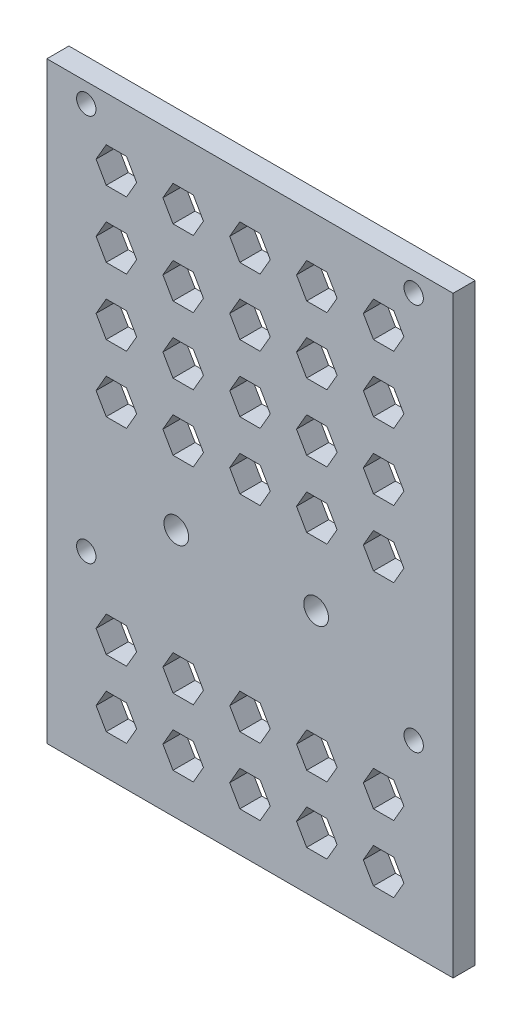
from build123d import *

# Parameters (mm, degrees)
SKETCH_1_W      = 60.8
SKETCH_1_H      = 88.755814015
SKETCH_1_R      = 1.45
SKETCH_1_R_2    = 1.85
EXTRUDE_1_DEPTH = 3.3


with BuildPart() as part:
    # Sketch 1 → Extrude 1 (new body)
    with BuildSketch(Plane.XY):
        with Locations((1.326158038, -1.737600889)):
            Rectangle(SKETCH_1_W, SKETCH_1_H)
        Polygon((-15.638485556, -37.518581742), (-17.156163759, -40.147277499), (-20.191520165, -40.147277499), (-21.709198368, -37.518581742), (-20.191520165, -34.889885985), (-17.156163759, -34.889885985), align=None, mode=Mode.SUBTRACT)
        Polygon((-15.638485556, -27.518581742), (-17.156163759, -30.147277499), (-20.191520165, -30.147277499), (-21.709198368, -27.518581742), (-20.191520165, -24.889885985), (-17.156163759, -24.889885985), align=None, mode=Mode.SUBTRACT)
        Polygon((-5.638485556, -37.518581742), (-7.156163759, -40.147277499), (-10.191520165, -40.147277499), (-11.709198368, -37.518581742), (-10.191520165, -34.889885985), (-7.156163759, -34.889885985), align=None, mode=Mode.SUBTRACT)
        Polygon((4.361514444, -37.518581742), (2.843836241, -40.147277499), (-0.191520165, -40.147277499), (-1.709198368, -37.518581742), (-0.191520165, -34.889885985), (2.843836241, -34.889885985), align=None, mode=Mode.SUBTRACT)
        Polygon((-5.638485556, -27.518581742), (-7.156163759, -30.147277499), (-10.191520165, -30.147277499), (-11.709198368, -27.518581742), (-10.191520165, -24.889885985), (-7.156163759, -24.889885985), align=None, mode=Mode.SUBTRACT)
        Polygon((4.361514444, -27.518581742), (2.843836241, -30.147277499), (-0.191520165, -30.147277499), (-1.709198368, -27.518581742), (-0.191520165, -24.889885985), (2.843836241, -24.889885985), align=None, mode=Mode.SUBTRACT)
        with Locations((-23.173841962, -18.259693882)):
            Circle(SKETCH_1_R, mode=Mode.SUBTRACT)
        with Locations((-9.7, -8.761035422)):
            Circle(SKETCH_1_R_2, mode=Mode.SUBTRACT)
        Polygon((14.361514444, -37.518581742), (12.843836241, -40.147277499), (9.808479835, -40.147277499), (8.290801632, -37.518581742), (9.808479835, -34.889885985), (12.843836241, -34.889885985), align=None, mode=Mode.SUBTRACT)
        Polygon((14.361514444, -27.518581742), (12.843836241, -30.147277499), (9.808479835, -30.147277499), (8.290801632, -27.518581742), (9.808479835, -24.889885985), (12.843836241, -24.889885985), align=None, mode=Mode.SUBTRACT)
        Polygon((24.361514444, -37.518581742), (22.843836241, -40.147277499), (19.808479835, -40.147277499), (18.290801632, -37.518581742), (19.808479835, -34.889885985), (22.843836241, -34.889885985), align=None, mode=Mode.SUBTRACT)
        Polygon((24.361514444, -27.518581742), (22.843836241, -30.147277499), (19.808479835, -30.147277499), (18.290801632, -27.518581742), (19.808479835, -24.889885985), (22.843836241, -24.889885985), align=None, mode=Mode.SUBTRACT)
        with Locations((11.226158038, -8.761035422)):
            Circle(SKETCH_1_R_2, mode=Mode.SUBTRACT)
        Polygon((-15.638485556, 3.308390173), (-17.156163759, 0.679694416), (-20.191520165, 0.679694416), (-21.709198368, 3.308390173), (-20.191520165, 5.93708593), (-17.156163759, 5.93708593), align=None, mode=Mode.SUBTRACT)
        Polygon((-15.638485556, 13.308390173), (-17.156163759, 10.679694416), (-20.191520165, 10.679694416), (-21.709198368, 13.308390173), (-20.191520165, 15.93708593), (-17.156163759, 15.93708593), align=None, mode=Mode.SUBTRACT)
        Polygon((-5.638485556, 3.308390173), (-7.156163759, 0.679694416), (-10.191520165, 0.679694416), (-11.709198368, 3.308390173), (-10.191520165, 5.93708593), (-7.156163759, 5.93708593), align=None, mode=Mode.SUBTRACT)
        Polygon((4.361514444, 3.308390173), (2.843836241, 0.679694416), (-0.191520165, 0.679694416), (-1.709198368, 3.308390173), (-0.191520165, 5.93708593), (2.843836241, 5.93708593), align=None, mode=Mode.SUBTRACT)
        Polygon((-5.638485556, 13.308390173), (-7.156163759, 10.679694416), (-10.191520165, 10.679694416), (-11.709198368, 13.308390173), (-10.191520165, 15.93708593), (-7.156163759, 15.93708593), align=None, mode=Mode.SUBTRACT)
        Polygon((4.361514444, 13.308390173), (2.843836241, 10.679694416), (-0.191520165, 10.679694416), (-1.709198368, 13.308390173), (-0.191520165, 15.93708593), (2.843836241, 15.93708593), align=None, mode=Mode.SUBTRACT)
        Polygon((-15.638485556, 23.308390173), (-17.156163759, 20.679694416), (-20.191520165, 20.679694416), (-21.709198368, 23.308390173), (-20.191520165, 25.93708593), (-17.156163759, 25.93708593), align=None, mode=Mode.SUBTRACT)
        Polygon((-15.638485556, 33.308390173), (-17.156163759, 30.679694416), (-20.191520165, 30.679694416), (-21.709198368, 33.308390173), (-20.191520165, 35.93708593), (-17.156163759, 35.93708593), align=None, mode=Mode.SUBTRACT)
        with Locations((-23.173841962, 39.740306118)):
            Circle(SKETCH_1_R, mode=Mode.SUBTRACT)
        Polygon((-5.638485556, 23.308390173), (-7.156163759, 20.679694416), (-10.191520165, 20.679694416), (-11.709198368, 23.308390173), (-10.191520165, 25.93708593), (-7.156163759, 25.93708593), align=None, mode=Mode.SUBTRACT)
        Polygon((4.361514444, 23.308390173), (2.843836241, 20.679694416), (-0.191520165, 20.679694416), (-1.709198368, 23.308390173), (-0.191520165, 25.93708593), (2.843836241, 25.93708593), align=None, mode=Mode.SUBTRACT)
        Polygon((-5.638485556, 33.308390173), (-7.156163759, 30.679694416), (-10.191520165, 30.679694416), (-11.709198368, 33.308390173), (-10.191520165, 35.93708593), (-7.156163759, 35.93708593), align=None, mode=Mode.SUBTRACT)
        Polygon((4.361514444, 33.308390173), (2.843836241, 30.679694416), (-0.191520165, 30.679694416), (-1.709198368, 33.308390173), (-0.191520165, 35.93708593), (2.843836241, 35.93708593), align=None, mode=Mode.SUBTRACT)
        Polygon((14.361514444, 3.308390173), (12.843836241, 0.679694416), (9.808479835, 0.679694416), (8.290801632, 3.308390173), (9.808479835, 5.93708593), (12.843836241, 5.93708593), align=None, mode=Mode.SUBTRACT)
        Polygon((14.361514444, 13.308390173), (12.843836241, 10.679694416), (9.808479835, 10.679694416), (8.290801632, 13.308390173), (9.808479835, 15.93708593), (12.843836241, 15.93708593), align=None, mode=Mode.SUBTRACT)
        Polygon((24.361514444, 3.308390173), (22.843836241, 0.679694416), (19.808479835, 0.679694416), (18.290801632, 3.308390173), (19.808479835, 5.93708593), (22.843836241, 5.93708593), align=None, mode=Mode.SUBTRACT)
        Polygon((24.361514444, 13.308390173), (22.843836241, 10.679694416), (19.808479835, 10.679694416), (18.290801632, 13.308390173), (19.808479835, 15.93708593), (22.843836241, 15.93708593), align=None, mode=Mode.SUBTRACT)
        Polygon((14.361514444, 23.308390173), (12.843836241, 20.679694416), (9.808479835, 20.679694416), (8.290801632, 23.308390173), (9.808479835, 25.93708593), (12.843836241, 25.93708593), align=None, mode=Mode.SUBTRACT)
        Polygon((14.361514444, 33.308390173), (12.843836241, 30.679694416), (9.808479835, 30.679694416), (8.290801632, 33.308390173), (9.808479835, 35.93708593), (12.843836241, 35.93708593), align=None, mode=Mode.SUBTRACT)
        Polygon((24.361514444, 23.308390173), (22.843836241, 20.679694416), (19.808479835, 20.679694416), (18.290801632, 23.308390173), (19.808479835, 25.93708593), (22.843836241, 25.93708593), align=None, mode=Mode.SUBTRACT)
        Polygon((24.361514444, 33.308390173), (22.843836241, 30.679694416), (19.808479835, 30.679694416), (18.290801632, 33.308390173), (19.808479835, 35.93708593), (22.843836241, 35.93708593), align=None, mode=Mode.SUBTRACT)
        with Locations((25.826158038, 39.740306118)):
            Circle(SKETCH_1_R, mode=Mode.SUBTRACT)
        with Locations((25.826158038, -18.259693882)):
            Circle(SKETCH_1_R, mode=Mode.SUBTRACT)
    extrude(amount=EXTRUDE_1_DEPTH)


solid = part.part
